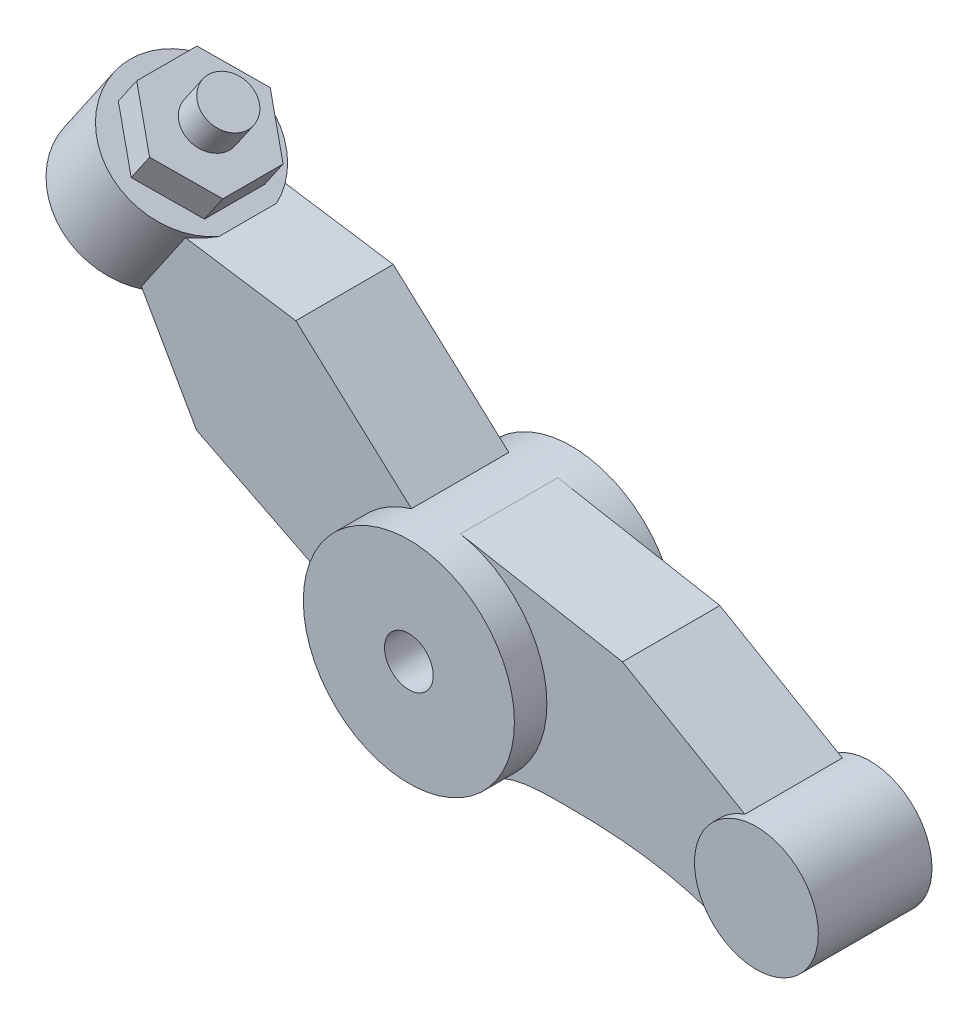
from build123d import *

# Parameters (mm, degrees)
SKETCH1_R           = 0.3
BOSS_EXTRUDE1_DEPTH = 1
SKETCH1_3_R         = 0.7625000000000004
BOSS_EXTRUDE2_DEPTH = 0.7
BOSS_EXTRUDE3_DEPTH = 0.6
BOSS_EXTRUDE4_DEPTH = 0.6
BOSS_EXTRUDE6_DEPTH = 0.4
SKETCH6_R           = 0.3000000000000001
BOSS_EXTRUDE7_DEPTH = 0.4


with BuildPart() as part:
    # Sketch1 → Boss-Extrude1 (new, symmetric)
    with BuildSketch(Plane.XY):
        with BuildLine():
            ThreePointArc((-1.295848634155192, -0.1038090427569955), (-0.5937418022379002, -1.1564906710714489), (0.6708713102684308, -1.113522197829356))
            ThreePointArc((0.6708713102684308, -1.113522197829356), (1.1318420171006551, -0.639479200854508), (1.3, -3.2e-16))
            ThreePointArc((1.3, 0), (0.9986616226828521, 0.8322709675222685), (0.23434621018391855, 1.2787031922117167))
            ThreePointArc((0.23434621018391855, 1.2787031922117167), (-0.0691085103528238, 1.2981617825975365), (-0.3687821609940866, 1.2465952501644355))
            ThreePointArc((-0.3687821609940866, 1.2465952501644355), (-1.0717494388265327, 0.7357670421913532), (-1.295848634155192, -0.1038090427569955))
        make_face()
        Circle(SKETCH1_R, mode=Mode.SUBTRACT)
    extrude(amount=BOSS_EXTRUDE1_DEPTH, both=True)



with BuildPart() as body_2:
    # Sketch1_3 → Boss-Extrude2 (new, symmetric)
    with BuildSketch(Plane.XY):
        with Locations((3.98, -0.682)):
            Circle(SKETCH1_3_R)
    extrude(amount=BOSS_EXTRUDE2_DEPTH, both=True)


with BuildPart() as part_1:
    add(part.part)

    add(body_2.part)  # Boss-Extrude3 merges body 2
    # Sketch1_4 → Boss-Extrude3 (add, symmetric)
    with BuildSketch(Plane.XY):
        with BuildLine():
            ThreePointArc((3.533365641715731, -1.3), (3.2261959128288145, -0.5671712224047641), (3.737636771810271, 0.04095664850767766))
            Line((3.737636771810271, 0.04095664850767755), (3.7381940341609177, 0.04114322570610333))
            Line((3.7381940341609177, 0.04114322570610333), (2.2303973924281215, 0.9128895829698543))
            Line((2.2303973924281215, 0.9128895829698543), (0.23434621018391844, 1.2787031922117167))
            ThreePointArc((0.23434621018391855, 1.2787031922117167), (0.9986616226828521, 0.8322709675222685), (1.3, 0))
            ThreePointArc((1.3, -3.2e-16), (1.1318420171006551, -0.639479200854508), (0.6708713102684308, -1.113522197829356))
            add(Edge.make_bspline(
                [(3.5333656417157315, -1.2999999999999996), (2.853592038907404, -1.0130142701138514), (1.9102895764787398, -0.9421538050015439), (0.888636742859566, -0.9823235729807698), (0.6708713102684306, -1.1135221978293557)],
                knots=[0, 0, 0, 0, 0.7400506262012527, 1, 1, 1, 1], degree=3))
        make_face()
    extrude(amount=BOSS_EXTRUDE3_DEPTH, both=True)

    # Sketch1_6 → Boss-Extrude4 (add, symmetric)
    with BuildSketch(Plane.XY):
        with BuildLine():
            Line((-3.0144803813987955, 0.759770763252125), (-1.2958486341551916, -0.10380904275699543))
            ThreePointArc((-1.295848634155192, -0.1038090427569955), (-1.0717494388265327, 0.7357670421913532), (-0.3687821609940866, 1.2465952501644355))
            Line((-0.36878216099408667, 1.2465952501644357), (-1.7922612424124467, 2.5401069311108047))
            Line((-1.7922612424124467, 2.5401069311108047), (-3.4680051646498034, 2.7932311357927926))
            Line((-3.4680051646498034, 2.7932311357927926), (-3.852867925180665, 2.2326237370219917))
            Line((-3.852867925180665, 2.2326237370219917), (-3.0144803813987955, 0.7597707632521251))
        make_face()
    extrude(amount=BOSS_EXTRUDE4_DEPTH, both=True)



with BuildPart() as body_2_2:
    # Sketch2 → Revolve1 (revolve)
    with BuildSketch(Plane.XY):
        with BuildLine():
            Line((-3.8528679251806657, 2.2326237370219917), (-3.445366178736224, 2.82620804160284))
            Line((-3.445366178736224, 2.82620804160284), (-3.775135236836695, 3.052597900738641))
            Line((-3.775135236836695, 3.052597900738641), (-4.837794634960111, 1.5046832099548804))
            ThreePointArc((-4.837794634960111, 1.5046832099548804), (-4.411503380011568, 1.52785460803016), (-4.324738796734218, 1.9458654390179164))
            Line((-4.324738796734218, 1.9458654390179164), (-3.8528679251806657, 2.2326237370219917))
        make_face()
    revolve(axis=Axis((-3.775135236836695, 3.052597900738641, 0), (-0.5659746478395029, -0.8244226452511787, 0)))


with BuildPart() as part_2:
    add(part_1.part)

    add(body_2_2.part)  # Revolve2 merges body 2 2
    # Sketch3 → Revolve2 (revolve)
    with BuildSketch(Plane.XY):
        Polygon((-4.429411479514997, 3.7126978729057627), (-3.67671360440067, 3.195963019428297), (-4.285702325475976, 2.3088842531380287), (-5.038400200590302, 2.8256191066154948), align=None)
    revolve(axis=Axis((-3.67671360440067, 3.195963019428297, 0), (-0.5659746478395032, -0.8244226452511785, 0)))

    # Sketch4 → Boss-Extrude6 (add)
    with BuildSketch(Plane(origin=(0.313491998615034, 0.4566457238851012, 0), x_dir=(0.8244226452511784, -0.5659746478395034, 0), z_dir=(0.5659746478395032, 0.8244226452511783, 0))):
        Polygon((-5.4833075288067565, -0.3714137749282946), (-4.840000000000001, -0.7428275498565884), (-4.196692471193242, -0.3714137749282935), (-4.196692471193242, 0.37141377492829386), (-4.84, 0.7428275498565884), (-5.4833075288067565, 0.3714137749282939), align=None)
    extrude(amount=BOSS_EXTRUDE6_DEPTH)

    # Sketch6 → Boss-Extrude7 (add)
    with BuildSketch(Plane(origin=(0.5398818577508345, 0.7864147819855706, 0), x_dir=(0.824422645251178, -0.5659746478395038, 0), z_dir=(0.5659746478395038, 0.824422645251178, 0))):
        with Locations((-4.840000000000002, 0)):
            Circle(SKETCH6_R)
    extrude(amount=BOSS_EXTRUDE7_DEPTH)


solid = part_2.part
